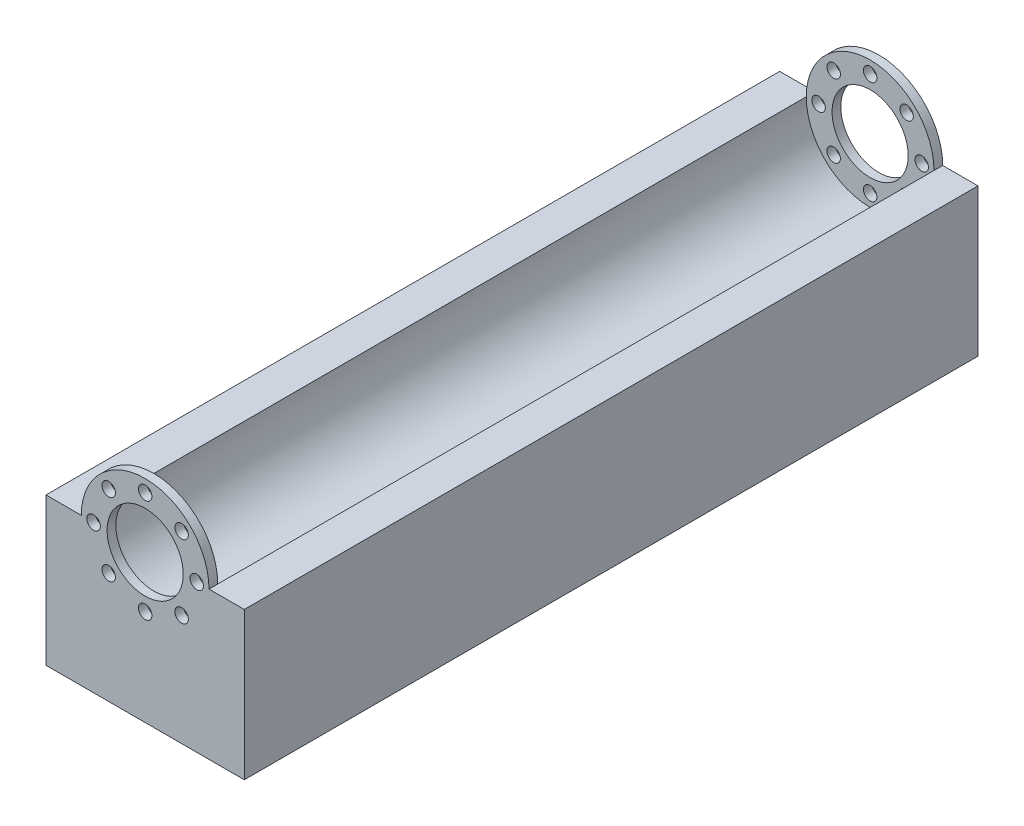
from build123d import *

# Parameters (mm, degrees)
BOSS_EXTRU_1_DEPTH = 92.5
ESQUISSE2_R        = 16.1
ESQUISSE2_R_2      = 1.7
ESQUISSE2_R_3      = 9.6
BOSS_EXTRU_2_DEPTH = 2.2


with BuildPart() as part:
    # Esquisse1 → Boss.-Extru.1 (new body, symmetric)
    with BuildSketch(Plane.XY):
        with BuildLine():
            Line((-25, 0), (-25, -37.200306763))
            Line((-25, -37.200306763), (25, -37.200306763))
            Line((25, -37.200306763), (25, 0))
            Line((25, 0), (16.1, 0))
            ThreePointArc((16.1, 0), (0, -16.1), (-16.1, 0))
            Line((-16.1, 0), (-25, 0))
        make_face()
    extrude(amount=BOSS_EXTRU_1_DEPTH, both=True)

    # Esquisse2 → Boss.-Extru.2 (add)
    with BuildSketch(Plane.XY.offset(92.5)):
        Circle(ESQUISSE2_R)
        with Locations((0, 13)):
            Circle(ESQUISSE2_R_2, mode=Mode.SUBTRACT)
        Circle(ESQUISSE2_R_3, mode=Mode.SUBTRACT)
        with Locations((9.192388155, 9.192388155)):
            Circle(ESQUISSE2_R_2, mode=Mode.SUBTRACT)
        with Locations((13, 0)):
            Circle(ESQUISSE2_R_2, mode=Mode.SUBTRACT)
        with Locations((9.192388155, -9.192388155)):
            Circle(ESQUISSE2_R_2, mode=Mode.SUBTRACT)
        with Locations((0, -13)):
            Circle(ESQUISSE2_R_2, mode=Mode.SUBTRACT)
        with Locations((-9.192388155, -9.192388155)):
            Circle(ESQUISSE2_R_2, mode=Mode.SUBTRACT)
        with Locations((-13, 0)):
            Circle(ESQUISSE2_R_2, mode=Mode.SUBTRACT)
        with Locations((-9.192388155, 9.192388155)):
            Circle(ESQUISSE2_R_2, mode=Mode.SUBTRACT)
    boss_extru_2 = extrude(amount=-BOSS_EXTRU_2_DEPTH)

    # Symétrie1: Boss.-Extru.2 across plane
    add(boss_extru_2.mirror(Plane.XY))


solid = part.part
